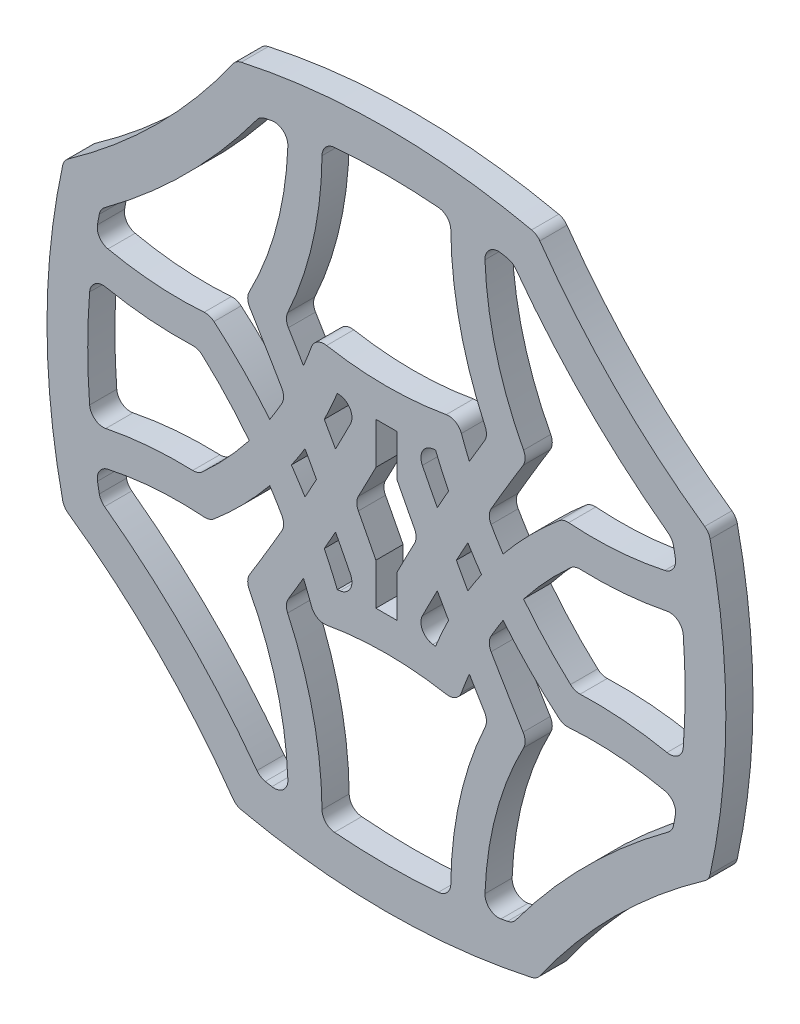
from build123d import *

# Parameters (mm, degrees)
EXTRUDE_2_DEPTH = 4
FILLET_1_R      = 2


with BuildPart() as part:
    # 草图1 → 凸台-拉伸2 (new body)
    with BuildSketch(Plane.XY):
        with BuildLine():
            ThreePointArc((-22.156412682, 47.514580331), (0, 50), (22.156412682, 47.514580331))
            ThreePointArc((22.156412682, 47.514580331), (33.689470571, 33.689470571), (47.514580331, 22.156412682))
            ThreePointArc((47.514580331, 22.156412682), (50, 0), (47.514580331, -22.156412682))
            ThreePointArc((47.514580331, -22.156412682), (33.689470571, -33.689470571), (22.156412682, -47.514580331))
            ThreePointArc((22.156412682, -47.514580331), (0, -50), (-22.156412682, -47.514580331))
            ThreePointArc((-22.156412682, -47.514580331), (-33.689470571, -33.689470571), (-47.514580331, -22.156412682))
            ThreePointArc((-47.514580331, -22.156412682), (-50, 0), (-47.514580331, 22.156412682))
            ThreePointArc((-47.514580331, 22.156412682), (-33.689470571, 33.689470571), (-22.156412682, 47.514580331))
        make_face()
        with BuildLine():
            Line((1.55, 12.05), (-1.55, 12.05))
            Line((-1.55, 12.05), (-1.55, 5.922613429))
            ThreePointArc((-1.55, 5.922613429), (-3.077162977, 2.954249222), (-4.631455213, 0))
            ThreePointArc((-4.631455213, 0), (-3.077162977, -2.954249222), (-1.55, -5.922613429))
            Line((-1.55, -5.922613429), (-1.55, -12.05))
            Line((-1.55, -12.05), (1.55, -12.05))
            Line((1.55, -12.05), (1.55, -5.922613429))
            ThreePointArc((1.55, -5.922613429), (3.077162977, -2.954249222), (4.631455213, 0))
            ThreePointArc((4.631455213, 0), (3.077162977, 2.954249222), (1.55, 5.922613429))
            Line((1.55, 5.922613429), (1.55, 12.05))
        make_face(mode=Mode.SUBTRACT)
        with BuildLine():
            ThreePointArc((-18.612398519, 42.138909378), (-16.554763888, 42.530750524), (-14.488909206, 42.876646742))
            ThreePointArc((-14.488909206, 42.876646742), (-15.99143101, 30.030747932), (-20.738618829, 18))
            ThreePointArc((-20.738618829, 18), (-17.753468678, 13.089591317), (-14.847215583, 8.132079057))
            ThreePointArc((-14.847215583, 8.132079057), (-15.978744964, 6.157357995), (-17.184296571, 4.226936452))
            ThreePointArc((-17.184296571, 4.226936452), (-21.39868588, 8.892170268), (-26.043775909, 13.128751722))
            ThreePointArc((-26.043775909, 13.128751722), (-34.517901242, 13.095162393), (-42.875990289, 14.493116569))
            ThreePointArc((-42.875990289, 14.493116569), (-42.530375529, 16.556859738), (-42.138909378, 18.612398519))
            ThreePointArc((-42.138909378, 18.612398519), (-29.446829884, 29.446829884), (-18.612398519, 42.138909378))
        make_face(mode=Mode.SUBTRACT)
        with BuildLine():
            ThreePointArc((42.138909378, 18.612398519), (42.530375529, 16.556859738), (42.875990289, 14.493116569))
            ThreePointArc((42.875990289, 14.493116569), (34.517901242, 13.095162393), (26.043775909, 13.128751722))
            ThreePointArc((26.043775909, 13.128751722), (21.39868588, 8.892170268), (17.184296571, 4.226936452))
            ThreePointArc((17.184296571, 4.226936452), (15.978744964, 6.157357995), (14.847215583, 8.132079057))
            ThreePointArc((14.847215583, 8.132079057), (17.753468678, 13.089591317), (20.738618829, 18))
            ThreePointArc((20.738618829, 18), (15.99143101, 30.030747932), (14.488909206, 42.876646742))
            ThreePointArc((14.488909206, 42.876646742), (16.554763888, 42.530750524), (18.612398519, 42.138909378))
            ThreePointArc((18.612398519, 42.138909378), (29.446829884, 29.446829884), (42.138909378, 18.612398519))
        make_face(mode=Mode.SUBTRACT)
        with BuildLine():
            ThreePointArc((18.612398519, -42.138909378), (16.554763888, -42.530750524), (14.488909206, -42.876646742))
            ThreePointArc((14.488909206, -42.876646742), (15.99143101, -30.030747932), (20.738618829, -18))
            ThreePointArc((20.738618829, -18), (17.753468678, -13.089591317), (14.847215583, -8.132079057))
            ThreePointArc((14.847215583, -8.132079057), (15.978744964, -6.157357995), (17.184296571, -4.226936452))
            ThreePointArc((17.184296571, -4.226936452), (21.39868588, -8.892170268), (26.043775909, -13.128751722))
            ThreePointArc((26.043775909, -13.128751722), (34.517901242, -13.095162393), (42.875990289, -14.493116569))
            ThreePointArc((42.875990289, -14.493116569), (42.530375529, -16.556859738), (42.138909378, -18.612398519))
            ThreePointArc((42.138909378, -18.612398519), (29.446829884, -29.446829884), (18.612398519, -42.138909378))
        make_face(mode=Mode.SUBTRACT)
        with BuildLine():
            ThreePointArc((-42.138909378, -18.612398519), (-42.530375529, -16.556859738), (-42.875990289, -14.493116569))
            ThreePointArc((-42.875990289, -14.493116569), (-34.517901242, -13.095162393), (-26.043775909, -13.128751722))
            ThreePointArc((-26.043775909, -13.128751722), (-21.39868588, -8.892170268), (-17.184296571, -4.226936452))
            ThreePointArc((-17.184296571, -4.226936452), (-15.978744964, -6.157357995), (-14.847215583, -8.132079057))
            ThreePointArc((-14.847215583, -8.132079057), (-17.753468678, -13.089591317), (-20.738618829, -18))
            ThreePointArc((-20.738618829, -18), (-15.99143101, -30.030747932), (-14.488909206, -42.876646742))
            ThreePointArc((-14.488909206, -42.876646742), (-16.554763888, -42.530750524), (-18.612398519, -42.138909378))
            ThreePointArc((-18.612398519, -42.138909378), (-29.446829884, -29.446829884), (-42.138909378, -18.612398519))
        make_face(mode=Mode.SUBTRACT)
        with BuildLine():
            ThreePointArc((10.485763424, 18.161875006), (0, 17.05), (-10.485763424, 18.161875006))
            ThreePointArc((-10.485763424, 18.161875006), (-11.305099174, 15.841771263), (-12.218799112, 13.557182706))
            ThreePointArc((-12.218799112, 13.557182706), (-13.600754873, 15.887596529), (-15, 18.207670534))
            ThreePointArc((-15, 18.207670534), (-10.738754192, 30.534804273), (-9.5, 43.518714705))
            ThreePointArc((-9.5, 43.518714705), (0, 44), (9.5, 43.518714705))
            ThreePointArc((9.5, 43.518714705), (10.738754192, 30.534804273), (15, 18.207670534))
            ThreePointArc((15, 18.207670534), (13.600754873, 15.887596529), (12.218799112, 13.557182706))
            ThreePointArc((12.218799112, 13.557182706), (11.305099174, 15.841771263), (10.485763424, 18.161875006))
        make_face(mode=Mode.SUBTRACT)
        with BuildLine():
            ThreePointArc((7.232845852, 12.527656499), (5.618875688, 12.337768863), (4, 12.195647392))
            ThreePointArc((4, 12.195647392), (5.731386961, 8.73163304), (7.5, 5.286476417))
            ThreePointArc((7.5, 5.286476417), (8.323836179, 6.767152545), (9.154548777, 8.243981724))
            ThreePointArc((9.154548777, 8.243981724), (8.155035506, 10.368475005), (7.232845852, 12.527656499))
        make_face(mode=Mode.SUBTRACT)
        with BuildLine():
            ThreePointArc((7.232845852, -12.527656499), (5.618875688, -12.337768863), (4, -12.195647392))
            ThreePointArc((4, -12.195647392), (5.731386961, -8.73163304), (7.5, -5.286476417))
            ThreePointArc((7.5, -5.286476417), (8.323836179, -6.767152545), (9.154548777, -8.243981724))
            ThreePointArc((9.154548777, -8.243981724), (8.155035506, -10.368475005), (7.232845852, -12.527656499))
        make_face(mode=Mode.SUBTRACT)
        with BuildLine():
            ThreePointArc((10.485763424, -18.161875006), (0, -17.05), (-10.485763424, -18.161875006))
            ThreePointArc((-10.485763424, -18.161875006), (-11.305099174, -15.841771263), (-12.218799112, -13.557182706))
            ThreePointArc((-12.218799112, -13.557182706), (-13.600754873, -15.887596529), (-15, -18.207670534))
            ThreePointArc((-15, -18.207670534), (-10.738754192, -30.534804273), (-9.5, -43.518714705))
            ThreePointArc((-9.5, -43.518714705), (0, -44), (9.5, -43.518714705))
            ThreePointArc((9.5, -43.518714705), (10.738754192, -30.534804273), (15, -18.207670534))
            ThreePointArc((15, -18.207670534), (13.600754873, -15.887596529), (12.218799112, -13.557182706))
            ThreePointArc((12.218799112, -13.557182706), (11.305099174, -15.841771263), (10.485763424, -18.161875006))
        make_face(mode=Mode.SUBTRACT)
        with BuildLine():
            ThreePointArc((-7.232845852, 12.527656499), (-8.155035506, 10.368475005), (-9.154548777, 8.243981724))
            ThreePointArc((-9.154548777, 8.243981724), (-8.323836179, 6.767152545), (-7.5, 5.286476417))
            ThreePointArc((-7.5, 5.286476417), (-5.731386961, 8.73163304), (-4, 12.195647392))
            ThreePointArc((-4, 12.195647392), (-5.618875688, 12.337768863), (-7.232845852, 12.527656499))
        make_face(mode=Mode.SUBTRACT)
        with BuildLine():
            ThreePointArc((-43.518714705, -9.5), (-35.682892851, -8.17851765), (-27.738426149, -8))
            ThreePointArc((-27.738426149, -8), (-23.788289079, -4.172697236), (-20.204934911, 0))
            ThreePointArc((-20.204934911, 0), (-23.788289079, 4.172697236), (-27.738426149, 8))
            ThreePointArc((-27.738426149, 8), (-35.682892851, 8.17851765), (-43.518714705, 9.5))
            ThreePointArc((-43.518714705, 9.5), (-44, 0), (-43.518714705, -9.5))
        make_face(mode=Mode.SUBTRACT)
        with BuildLine():
            ThreePointArc((-7.232845852, -12.527656499), (-8.155035506, -10.368475005), (-9.154548777, -8.243981724))
            ThreePointArc((-9.154548777, -8.243981724), (-8.323836179, -6.767152545), (-7.5, -5.286476417))
            ThreePointArc((-7.5, -5.286476417), (-5.731386961, -8.73163304), (-4, -12.195647392))
            ThreePointArc((-4, -12.195647392), (-5.618875688, -12.337768863), (-7.232845852, -12.527656499))
        make_face(mode=Mode.SUBTRACT)
        with BuildLine():
            ThreePointArc((20.204934911, 0), (23.788289079, 4.172697236), (27.738426149, 8))
            ThreePointArc((27.738426149, 8), (35.682892851, 8.17851765), (43.518714705, 9.5))
            ThreePointArc((43.518714705, 9.5), (44, 0), (43.518714705, -9.5))
            ThreePointArc((43.518714705, -9.5), (35.682892851, -8.17851765), (27.738426149, -8))
            ThreePointArc((27.738426149, -8), (23.788289079, -4.172697236), (20.204934911, 0))
        make_face(mode=Mode.SUBTRACT)
        with BuildLine():
            ThreePointArc((-11.995024392, -3.082589715), (-12.975724151, -1.527123494), (-14, 0))
            ThreePointArc((-14, 0), (-12.975724151, 1.527123494), (-11.995024392, 3.082589715))
            ThreePointArc((-11.995024392, 3.082589715), (-11.146815078, 1.543359614), (-10.306143059, 0))
            ThreePointArc((-10.306143059, 0), (-11.146815078, -1.543359614), (-11.995024392, -3.082589715))
        make_face(mode=Mode.SUBTRACT)
        with BuildLine():
            ThreePointArc((11.995024392, -3.082589715), (12.975724151, -1.527123494), (14, 0))
            ThreePointArc((14, 0), (12.975724151, 1.527123494), (11.995024392, 3.082589715))
            ThreePointArc((11.995024392, 3.082589715), (11.146815078, 1.543359614), (10.306143059, 0))
            ThreePointArc((10.306143059, 0), (11.146815078, -1.543359614), (11.995024392, -3.082589715))
        make_face(mode=Mode.SUBTRACT)
    extrude(amount=EXTRUDE_2_DEPTH)

    # 圆角1
    fillet_1_edges = [part.edges().sort_by_distance(p)[0] for p in [
        (-4, -12.195647392, 2),
        (4, -12.195647392, 2),
        (-10.485763424, 18.161875006, 2),
        (10.485763424, 18.161875006, 2),
        (15, 18.207670534, 2),
        (9.5, 43.518714705, 2),
        (-9.5, 43.518714705, 2),
        (-15, 18.207670534, 2),
        (20.738618829, -18, 2),
        (14.488909206, -42.876646742, 2),
        (18.612398519, -42.138909378, 2),
        (42.138909378, -18.612398519, 2),
        (42.875990289, -14.493116569, 2),
        (26.043775909, -13.128751722, 2),
        (14.847215583, -8.132079057, 2),
        (10.485763424, -18.161875006, 2),
        (-10.485763424, -18.161875006, 2),
        (-15, -18.207670534, 2),
        (-9.5, -43.518714705, 2),
        (9.5, -43.518714705, 2),
        (15, -18.207670534, 2),
        (-26.043775909, -13.128751722, 2),
        (-42.875990289, -14.493116569, 2),
        (-42.138909378, -18.612398519, 2),
        (-18.612398519, -42.138909378, 2),
        (-14.488909206, -42.876646742, 2),
        (-20.738618829, -18, 2),
        (-14.847215583, -8.132079057, 2),
        (27.738426149, 8, 2),
        (27.738426149, -8, 2),
        (43.518714705, -9.5, 2),
        (43.518714705, 9.5, 2),
        (-27.738426149, -8, 2),
        (-27.738426149, 8, 2),
        (-43.518714705, 9.5, 2),
        (-43.518714705, -9.5, 2),
        (-22.156412682, 47.514580331, 2),
        (22.156412682, 47.514580331, 2),
        (47.514580331, 22.156412682, 2),
        (47.514580331, -22.156412682, 2),
        (22.156412682, -47.514580331, 2),
        (-22.156412682, -47.514580331, 2),
        (-47.514580331, -22.156412682, 2),
        (-47.514580331, 22.156412682, 2),
        (-4.631455213, 0, 2),
        (4.631455213, 0, 2),
        (26.043775909, 13.128751722, 2),
        (42.875990289, 14.493116569, 2),
        (42.138909378, 18.612398519, 2),
        (18.612398519, 42.138909378, 2),
        (14.488909206, 42.876646742, 2),
        (20.738618829, 18, 2),
        (14.847215583, 8.132079057, 2),
        (-20.738618829, 18, 2),
        (-14.488909206, 42.876646742, 2),
        (-18.612398519, 42.138909378, 2),
        (-42.138909378, 18.612398519, 2),
        (-42.875990289, 14.493116569, 2),
        (-26.043775909, 13.128751722, 2),
        (-14.847215583, 8.132079057, 2),
        (4, 12.195647392, 2),
        (-4, 12.195647392, 2),
    ]]
    fillet(fillet_1_edges, radius=FILLET_1_R)


solid = part.part
